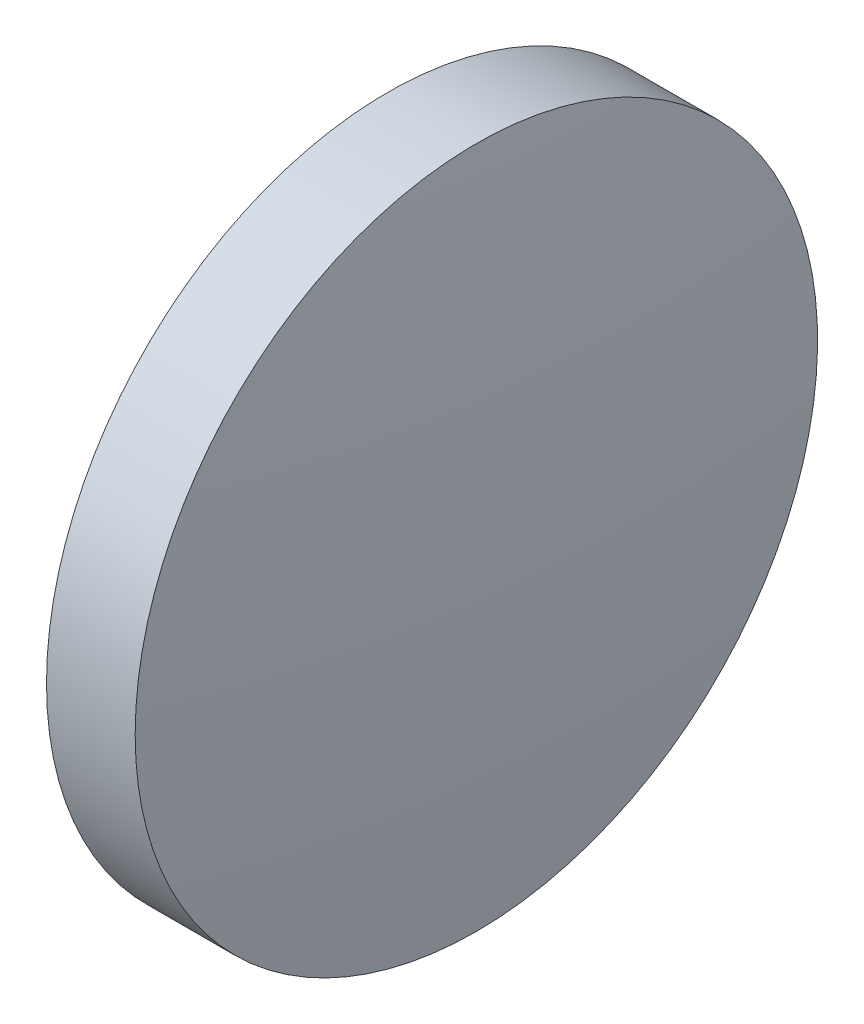
from build123d import *


with BuildPart() as part:
    # 草图1 → 旋转1 (revolve)
    with BuildSketch(Plane.XY, mode=Mode.PRIVATE) as revolve_1_sk:
        with BuildLine():
            Line((380.306904934, 118.350248119), (380.306904934, 131.050248119))
            Line((380.306904934, 131.050248119), (383.606904934, 131.050248119))
            ThreePointArc((383.606904934, 131.050248119), (384.131772223, 124.709886473), (384.306904934, 118.350248119))
            Line((384.306904934, 118.350248119), (380.306904934, 118.350248119))
        make_face()
    revolve(revolve_1_sk.sketch.rotate(Axis((374.677008883, 118.350248119, 0), (1, 0, 0)), 180), axis=Axis((374.677008883, 118.350248119, 0), (1, 0, 0)))  # turned: the seam where the file's is


solid = part.part
